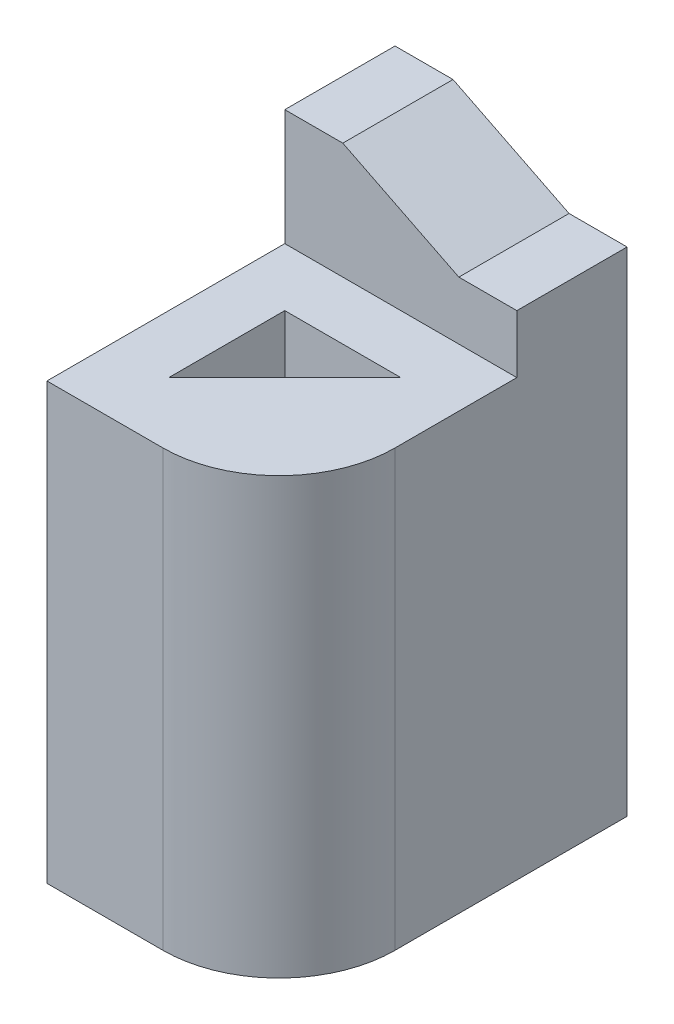
from build123d import *

# Parameters (mm, degrees)
BOSS_EXTRUDE1_DEPTH = 1905
SKETCH1_3_W         = 1016
SKETCH1_3_H         = 482.6
BOSS_EXTRUDE2_DEPTH = 2413
CUT_EXTRUDE1_DEPTH  = 482.6


with BuildPart() as part:
    # Sketch1 → Boss-Extrude1 (new body)
    with BuildSketch(Plane(origin=(0, 0, 0), x_dir=(1, 0, 0), z_dir=(0, 1, 0))):
        with BuildLine():
            Line((1016, -482.6), (0, -482.6))
            Line((0, -482.6), (0, -1524))
            Line((0, -1524), (508, -1524))
            ThreePointArc((508, -1524), (867.210244843, -1375.210244843), (1016, -1016))
            Line((1016, -1016), (1016, -482.6))
        make_face()
        Polygon((254, -1244.6), (254, -736.6), (762, -736.6), align=None, mode=Mode.SUBTRACT)
    extrude(amount=BOSS_EXTRUDE1_DEPTH)

    # Sketch1_3 → Boss-Extrude2 (add)
    with BuildSketch(Plane(origin=(0, 0, 0), x_dir=(1, 0, 0), z_dir=(0, 1, 0))):
        with Locations((508, -241.3)):
            Rectangle(SKETCH1_3_W, SKETCH1_3_H)
    extrude(amount=BOSS_EXTRUDE2_DEPTH)

    # Sketch2 → Cut-Extrude1 (cut)
    with BuildSketch(Plane.XY.offset(482.6)):
        Polygon((254, 2413), (762, 2159), (1016, 2159), (1016, 2413), align=None)
    extrude(amount=-CUT_EXTRUDE1_DEPTH, mode=Mode.SUBTRACT)


solid = part.part
